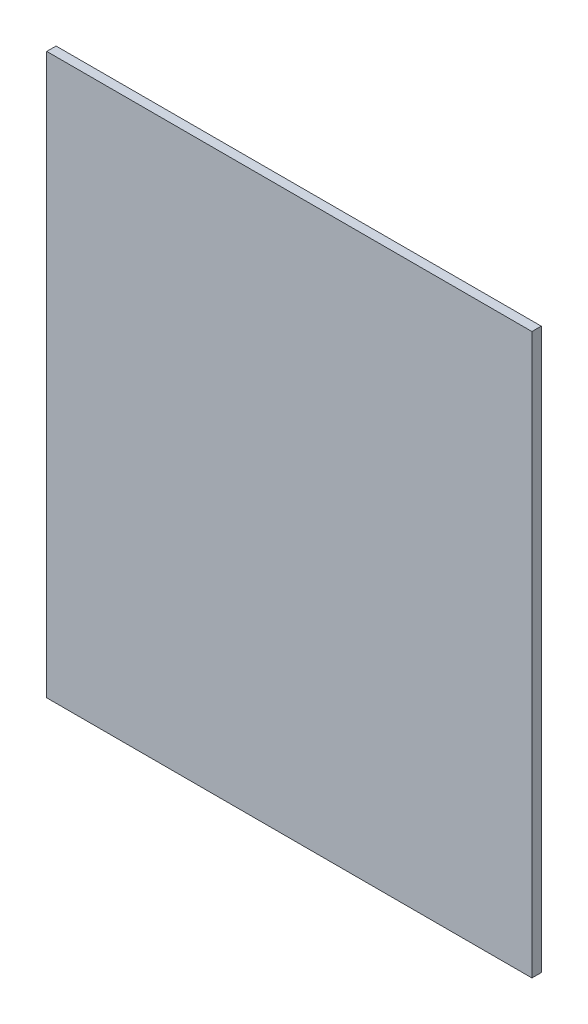
from build123d import *

# Parameters (mm, degrees)
SKETCH1_W           = 330.2
SKETCH1_H           = 381
BOSS_EXTRUDE1_DEPTH = 3.175


with BuildPart() as part:
    # Sketch1 → Boss-Extrude1 (new body, symmetric)
    with BuildSketch(Plane.XY):
        Rectangle(SKETCH1_W, SKETCH1_H)
    extrude(amount=BOSS_EXTRUDE1_DEPTH, both=True)


solid = part.part
